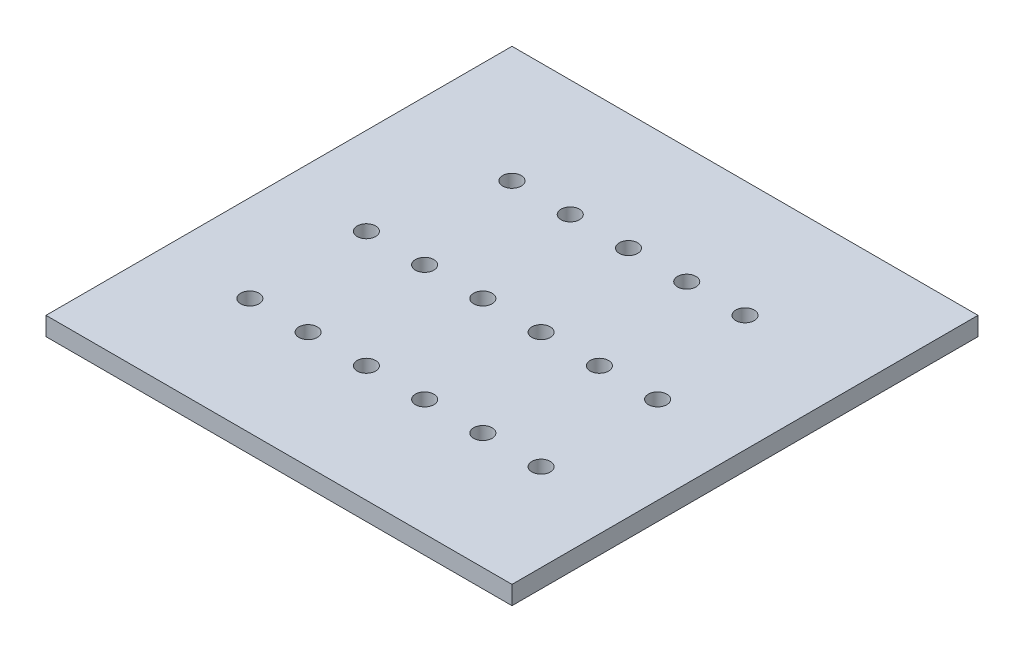
from build123d import *

# Parameters (mm, degrees)
SKETCH1_W           = 120
SKETCH1_H           = 120
SKETCH1_R           = 2.375
BOSS_EXTRUDE1_DEPTH = 4.7625


with BuildPart() as part:
    # Sketch1 → Boss-Extrude1 (new body)
    with BuildSketch(Plane(origin=(0, 0, 0), x_dir=(1, 0, 0), z_dir=(0, 1, 0))):
        with Locations((60, 60)):
            Rectangle(SKETCH1_W, SKETCH1_H)
        with Locations((30, 90)):
            Circle(SKETCH1_R, mode=Mode.SUBTRACT)
        with Locations((45, 90)):
            Circle(SKETCH1_R, mode=Mode.SUBTRACT)
        with Locations((60, 90)):
            Circle(SKETCH1_R, mode=Mode.SUBTRACT)
        with Locations((75, 90)):
            Circle(SKETCH1_R, mode=Mode.SUBTRACT)
        with Locations((90, 90)):
            Circle(SKETCH1_R, mode=Mode.SUBTRACT)
        with Locations((97.5, 60)):
            Circle(SKETCH1_R, mode=Mode.SUBTRACT)
        with Locations((82.5, 60)):
            Circle(SKETCH1_R, mode=Mode.SUBTRACT)
        with Locations((67.5, 60)):
            Circle(SKETCH1_R, mode=Mode.SUBTRACT)
        with Locations((52.5, 60)):
            Circle(SKETCH1_R, mode=Mode.SUBTRACT)
        with Locations((37.5, 60)):
            Circle(SKETCH1_R, mode=Mode.SUBTRACT)
        with Locations((22.5, 30)):
            Circle(SKETCH1_R, mode=Mode.SUBTRACT)
        with Locations((37.5, 30)):
            Circle(SKETCH1_R, mode=Mode.SUBTRACT)
        with Locations((52.5, 30)):
            Circle(SKETCH1_R, mode=Mode.SUBTRACT)
        with Locations((67.5, 30)):
            Circle(SKETCH1_R, mode=Mode.SUBTRACT)
        with Locations((82.5, 30)):
            Circle(SKETCH1_R, mode=Mode.SUBTRACT)
        with Locations((97.5, 30)):
            Circle(SKETCH1_R, mode=Mode.SUBTRACT)
        with Locations((22.5, 60)):
            Circle(SKETCH1_R, mode=Mode.SUBTRACT)
    extrude(amount=BOSS_EXTRUDE1_DEPTH)


solid = part.part
